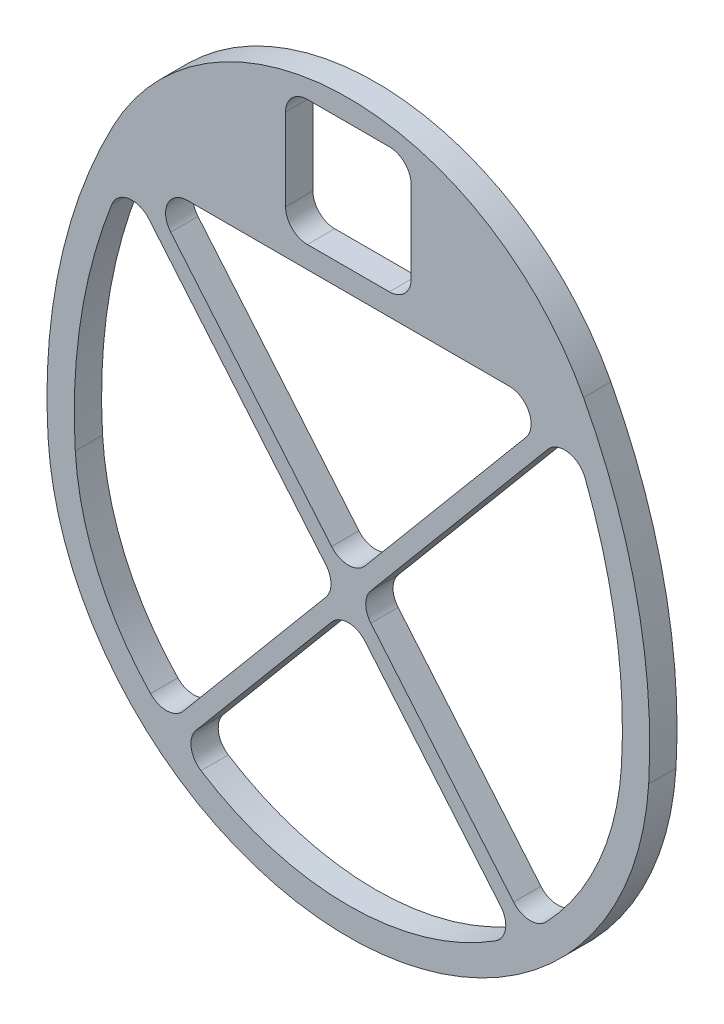
from build123d import *

# Parameters (mm, degrees)
BOSS_EXTRUDE1_DEPTH = 6.35
CUT_EXTRUDE1_REACH  = 8.35
SKETCH2_W           = 29.21
SKETCH2_H           = 29.21
FILLET1_R           = 5.08
BOSS_EXTRUDE2_DEPTH = 6.35
FILLET2_R           = 5.08


with BuildPart() as part:
    # Sketch1 → Boss-Extrude1 (new body)
    with BuildSketch(Plane.XY):
        with BuildLine():
            ThreePointArc((-54.695205109, 69.85), (-67.085998682, 35.772421109), (-69.83842006, -0.383315988))
            ThreePointArc((-69.83842006, -0.383315988), (0, -66.125848112), (69.83842006, -0.383315988))
            ThreePointArc((69.83842006, -0.383315988), (67.085998682, 35.772421109), (54.695205109, 69.85))
            ThreePointArc((54.695205109, 69.85), (0, 102.847096123), (-54.695205109, 69.85))
        make_face()
        with BuildLine():
            Line((-50.8, 63.5), (50.8, 63.5))
            ThreePointArc((50.8, 63.5), (61.265344619, 32.573068924), (63.5, 0))
            ThreePointArc((63.5, 0), (0, -59.775848112), (-63.5, 0))
            ThreePointArc((-63.5, 0), (-61.265344619, 32.573068924), (-50.8, 63.5))
        make_face(mode=Mode.SUBTRACT)
    extrude(amount=BOSS_EXTRUDE1_DEPTH)

    # Sketch2 → Cut-Extrude1 (cut, up to next)
    with BuildSketch(Plane.XY.offset(6.35), mode=Mode.PRIVATE) as cut_extrude1_sk1:
        with Locations((0, 83.173548061)):
            Rectangle(SKETCH2_W, SKETCH2_H)
    cut_extrude1_tool1 = extrude(cut_extrude1_sk1.sketch, amount=-CUT_EXTRUDE1_REACH, mode=Mode.PRIVATE) & part.part
    add(cut_extrude1_tool1.solids().sort_by_distance((0, 83.173548, 6.35))[0], mode=Mode.SUBTRACT)

    # Fillet1
    fillet1_edges = [part.edges().sort_by_distance(p)[0] for p in [
        (14.605, 97.778548061, 3.175),
        (14.605, 68.568548061, 3.175),
        (-14.605, 68.568548061, 3.175),
        (-14.605, 97.778548061, 3.175),
    ]]
    fillet(fillet1_edges, radius=FILLET1_R)

    # Sketch3 → Boss-Extrude2 (add)
    with BuildSketch(Plane.XY.offset(6.35)):
        with BuildLine():
            Line((48.313199114, 63.5), (0, 5.922571386))
            Line((0, 5.922571386), (2.486800886, 2.958917496))
            Line((2.486800886, 2.958917496), (51.704078268, 61.613784634))
            ThreePointArc((51.704078268, 61.613784634), (51.255922445, 62.55875362), (50.8, 63.5))
            Line((50.8, 63.5), (48.313199114, 63.5))
        make_face()
        with BuildLine():
            Line((-48.313199114, 63.5), (-50.8, 63.5))
            ThreePointArc((-50.8, 63.5), (-51.255922445, 62.55875362), (-51.704078268, 61.613784634))
            Line((-51.704078268, 61.613784634), (-2.486800886, 2.958917496))
            Line((-2.486800886, 2.958917496), (0, 5.922571386))
            Line((0, 5.922571386), (-48.313199114, 63.5))
        make_face()
        Polygon((0, 5.922571386), (-2.486800886, 2.958917496), (0, -0.004736394), (2.486800886, 2.958917496), align=None)
        with BuildLine():
            Line((2.486800886, 2.958917496), (0, -0.004736394))
            Line((0, -0.004736394), (38.967470095, -46.444358875))
            ThreePointArc((38.967470095, -46.444358875), (40.455837743, -45.254867888), (41.907916796, -44.021339013))
            Line((41.907916796, -44.021339013), (2.486800886, 2.958917496))
        make_face()
        with BuildLine():
            Line((0, -0.004736394), (-2.486800886, 2.958917496))
            Line((-2.486800886, 2.958917496), (-41.907916796, -44.021339013))
            ThreePointArc((-41.907916796, -44.021339013), (-40.455837743, -45.254867888), (-38.967470095, -46.444358875))
            Line((-38.967470095, -46.444358875), (0, -0.004736394))
        make_face()
    extrude(amount=-BOSS_EXTRUDE2_DEPTH)

    # Fillet2
    fillet2_edges = [part.edges().sort_by_distance(p)[0] for p in [
        (48.313199114, 63.5, 3.175),
        (0, 5.922571386, 3.175),
        (-48.313199114, 63.5, 3.175),
        (-51.704078268, 61.613784634, 3.175),
        (-2.486800886, 2.958917496, 3.175),
        (-41.907916796, -44.021339013, 3.175),
        (-38.967470095, -46.444358875, 3.175),
        (0, -0.004736394, 3.175),
        (38.967470095, -46.444358875, 3.175),
        (41.907916796, -44.021339013, 3.175),
        (2.486800886, 2.958917496, 3.175),
        (51.704078268, 61.613784634, 3.175),
    ]]
    fillet(fillet2_edges, radius=FILLET2_R)


solid = part.part
